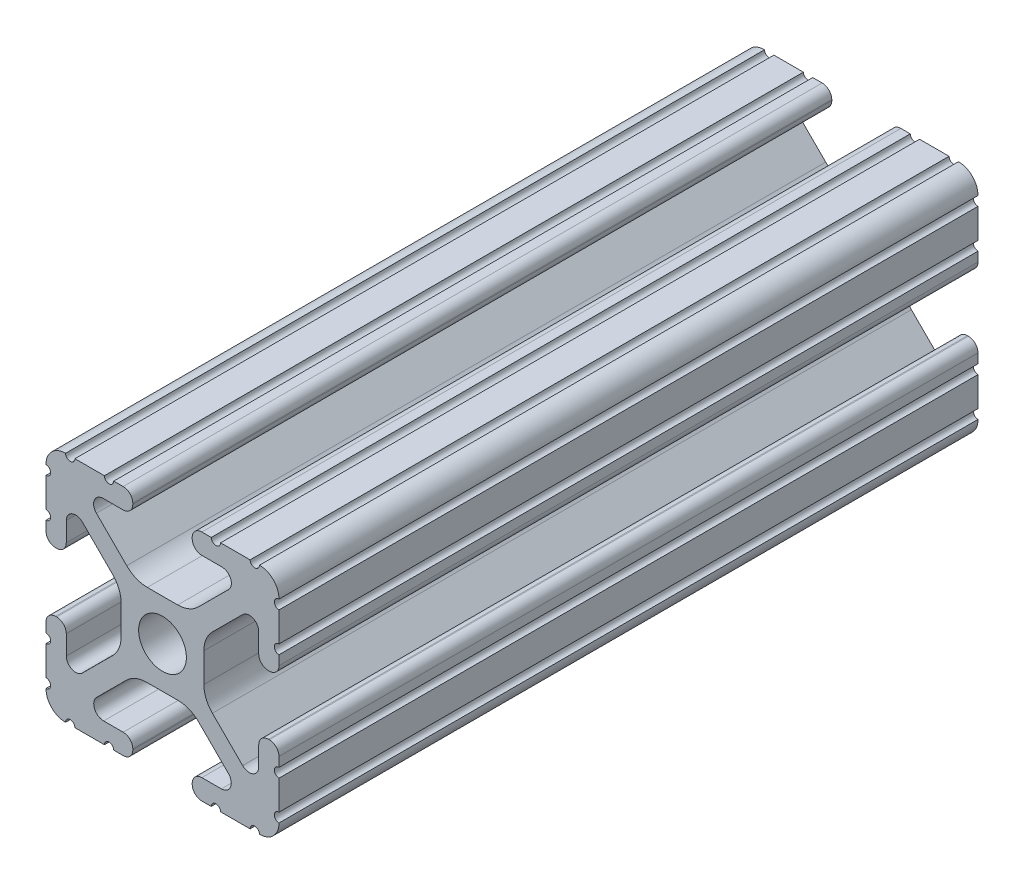
from build123d import *

# Parameters (mm, degrees)
SKETCH1_R      = 2.6035
EXTRUDE1_DEPTH = 76.2


with BuildPart() as part:
    # Sketch1 → Extrude1 (new body)
    with BuildSketch(Plane.XY):
        with BuildLine():
            Line((-7.207191475, 8.724540082), (-3.900315394, 5.423689619))
            ThreePointArc((-3.900315394, 5.423689619), (-2.8709819, 4.736928798), (-1.657299581, 4.4958))
            Line((-1.657299581, 4.4958), (1.657299581, 4.4958))
            ThreePointArc((1.657299581, 4.4958), (2.8709819, 4.736928798), (3.900315394, 5.423689619))
            Line((3.900315394, 5.423689619), (7.207191475, 8.724540082))
            ThreePointArc((7.207191475, 8.724540082), (7.43216212, 9.851515102), (6.476774195, 10.4902))
            Line((6.476774195, 10.4902), (4.2874692, 10.4902))
            ThreePointArc((4.2874692, 10.4902), (3.545700044, 10.797450844), (3.2384492, 11.53922))
            Line((3.2384492, 11.53922), (3.2384492, 11.65098))
            ThreePointArc((3.2384492, 11.65098), (3.545700044, 12.392749156), (4.2874692, 12.7))
            Line((4.2874692, 12.7), (5.3170836, 12.7))
            ThreePointArc((5.3170836, 12.7), (5.8250836, 12.192), (6.3330836, 12.7))
            Line((6.3330836, 12.7), (9.5504, 12.7))
            ThreePointArc((9.5504, 12.7), (10.058323491, 12.192000006), (10.566399977, 12.699846982))
            ThreePointArc((10.566399977, 12.699846982), (12.082522516, 12.082522516), (12.699846982, 10.566399977))
            ThreePointArc((12.699846982, 10.566399977), (12.192000006, 10.058323491), (12.7, 9.5504))
            Line((12.7, 9.5504), (12.7, 6.3331344))
            ThreePointArc((12.7, 6.3331344), (12.192, 5.8251344), (12.7, 5.3171344))
            Line((12.7, 5.3171344), (12.7, 4.287470133))
            ThreePointArc((12.7, 4.287470133), (12.392749156, 3.545700977), (11.65098, 3.238450133))
            Line((11.65098, 3.238450133), (11.53922, 3.238450133))
            ThreePointArc((11.53922, 3.238450133), (10.797450844, 3.545700977), (10.4902, 4.287470133))
            Line((10.4902, 4.287470133), (10.4902, 6.402089023))
            ThreePointArc((10.4902, 6.402089023), (9.856394933, 7.351113629), (8.736962546, 7.129240479))
            Line((8.736962546, 7.129240479), (5.440484187, 3.838768792))
            ThreePointArc((5.440484187, 3.838768792), (4.75073678, 2.808015636), (4.5085, 1.591658411))
            Line((4.5085, 1.591658411), (4.5085, -1.591658411))
            ThreePointArc((4.5085, -1.591658411), (4.75073678, -2.808015636), (5.440484187, -3.838768792))
            Line((5.440484187, -3.838768792), (8.736962546, -7.129240479))
            ThreePointArc((8.736962546, -7.129240479), (9.856394933, -7.351113629), (10.4902, -6.402089023))
            Line((10.4902, -6.402089023), (10.4902, -4.287470133))
            ThreePointArc((10.4902, -4.287470133), (10.797450844, -3.545700977), (11.53922, -3.238450133))
            Line((11.53922, -3.238450133), (11.65098, -3.238450133))
            ThreePointArc((11.65098, -3.238450133), (12.392749156, -3.545700977), (12.7, -4.287470133))
            Line((12.7, -4.287470133), (12.7, -5.3170836))
            ThreePointArc((12.7, -5.3170836), (12.192, -5.8250836), (12.7, -6.3330836))
            Line((12.7, -6.3330836), (12.7, -9.5504))
            ThreePointArc((12.7, -9.5504), (12.192000006, -10.058323491), (12.699846982, -10.566399977))
            ThreePointArc((12.699846982, -10.566399977), (12.082522516, -12.082522516), (10.566399977, -12.699846982))
            ThreePointArc((10.566399977, -12.699846982), (10.058323491, -12.192000006), (9.5504, -12.7))
            Line((9.5504, -12.7), (6.3331344, -12.7))
            ThreePointArc((6.3331344, -12.7), (5.8251344, -12.192), (5.3171344, -12.7))
            Line((5.3171344, -12.7), (4.28752, -12.7))
            ThreePointArc((4.28752, -12.7), (3.545750844, -12.392749156), (3.2385, -11.65098))
            Line((3.2385, -11.65098), (3.2385, -11.53922))
            ThreePointArc((3.2385, -11.53922), (3.545750844, -10.797450844), (4.28752, -10.4902))
            Line((4.28752, -10.4902), (6.41641086, -10.4902))
            ThreePointArc((6.41641086, -10.4902), (7.414733441, -9.822812921), (7.179652728, -8.645192207))
            Line((7.179652728, -8.645192207), (3.95226937, -5.423689619))
            ThreePointArc((3.95226937, -5.423689619), (2.922935876, -4.736928798), (1.709253557, -4.4958))
            Line((1.709253557, -4.4958), (-1.709253557, -4.4958))
            ThreePointArc((-1.709253557, -4.4958), (-2.922935876, -4.736928798), (-3.95226937, -5.423689619))
            Line((-3.95226937, -5.423689619), (-7.179652728, -8.645192207))
            ThreePointArc((-7.179652728, -8.645192207), (-7.414733441, -9.822812921), (-6.41641086, -10.4902))
            Line((-6.41641086, -10.4902), (-4.28752, -10.4902))
            ThreePointArc((-4.28752, -10.4902), (-3.545750844, -10.797450844), (-3.2385, -11.53922))
            Line((-3.2385, -11.53922), (-3.2385, -11.65098))
            ThreePointArc((-3.2385, -11.65098), (-3.545750844, -12.392749156), (-4.28752, -12.7))
            Line((-4.28752, -12.7), (-5.3171344, -12.7))
            ThreePointArc((-5.3171344, -12.7), (-5.8251344, -12.192), (-6.3331344, -12.7))
            Line((-6.3331344, -12.7), (-9.5504, -12.7))
            ThreePointArc((-9.5504, -12.7), (-10.058323491, -12.192000006), (-10.566399977, -12.699846982))
            ThreePointArc((-10.566399977, -12.699846982), (-12.082522516, -12.082522516), (-12.699846982, -10.566399977))
            ThreePointArc((-12.699846982, -10.566399977), (-12.192000006, -10.058323491), (-12.7, -9.5504))
            Line((-12.7, -9.5504), (-12.7, -6.3330836))
            ThreePointArc((-12.7, -6.3330836), (-12.192, -5.8250836), (-12.7, -5.3170836))
            Line((-12.7, -5.3170836), (-12.7, -4.287470133))
            ThreePointArc((-12.7, -4.287470133), (-12.392749156, -3.545700977), (-11.65098, -3.238450133))
            Line((-11.65098, -3.238450133), (-11.53922, -3.238450133))
            ThreePointArc((-11.53922, -3.238450133), (-10.797450844, -3.545700977), (-10.4902, -4.287470133))
            Line((-10.4902, -4.287470133), (-10.4902, -6.402089023))
            ThreePointArc((-10.4902, -6.402089023), (-9.856394933, -7.351113629), (-8.736962546, -7.129240479))
            Line((-8.736962546, -7.129240479), (-5.440484187, -3.838768792))
            ThreePointArc((-5.440484187, -3.838768792), (-4.75073678, -2.808015636), (-4.5085, -1.591658411))
            Line((-4.5085, -1.591658411), (-4.5085, 1.591658411))
            ThreePointArc((-4.5085, 1.591658411), (-4.75073678, 2.808015636), (-5.440484187, 3.838768792))
            Line((-5.440484187, 3.838768792), (-8.736962546, 7.129240479))
            ThreePointArc((-8.736962546, 7.129240479), (-9.856394933, 7.351113629), (-10.4902, 6.402089023))
            Line((-10.4902, 6.402089023), (-10.4902, 4.287470133))
            ThreePointArc((-10.4902, 4.287470133), (-10.797450844, 3.545700977), (-11.53922, 3.238450133))
            Line((-11.53922, 3.238450133), (-11.65098, 3.238450133))
            ThreePointArc((-11.65098, 3.238450133), (-12.392749156, 3.545700977), (-12.7, 4.287470133))
            Line((-12.7, 4.287470133), (-12.7, 5.3171344))
            ThreePointArc((-12.7, 5.3171344), (-12.192, 5.8251344), (-12.7, 6.3331344))
            Line((-12.7, 6.3331344), (-12.7, 9.5504))
            ThreePointArc((-12.7, 9.5504), (-12.192000006, 10.058323491), (-12.699846982, 10.566399977))
            ThreePointArc((-12.699846982, 10.566399977), (-12.082522516, 12.082522516), (-10.566399977, 12.699846982))
            ThreePointArc((-10.566399977, 12.699846982), (-10.058323491, 12.192000006), (-9.5504, 12.7))
            Line((-9.5504, 12.7), (-6.3330836, 12.7))
            ThreePointArc((-6.3330836, 12.7), (-5.8250836, 12.192), (-5.3170836, 12.7))
            Line((-5.3170836, 12.7), (-4.2874692, 12.7))
            ThreePointArc((-4.2874692, 12.7), (-3.545700044, 12.392749156), (-3.2384492, 11.65098))
            Line((-3.2384492, 11.65098), (-3.2384492, 11.53922))
            ThreePointArc((-3.2384492, 11.53922), (-3.545700044, 10.797450844), (-4.2874692, 10.4902))
            Line((-4.2874692, 10.4902), (-6.476774195, 10.4902))
            ThreePointArc((-6.476774195, 10.4902), (-7.43216212, 9.851515102), (-7.207191475, 8.724540082))
        make_face()
        Circle(SKETCH1_R, mode=Mode.SUBTRACT)
    extrude(amount=-EXTRUDE1_DEPTH)


solid = part.part
